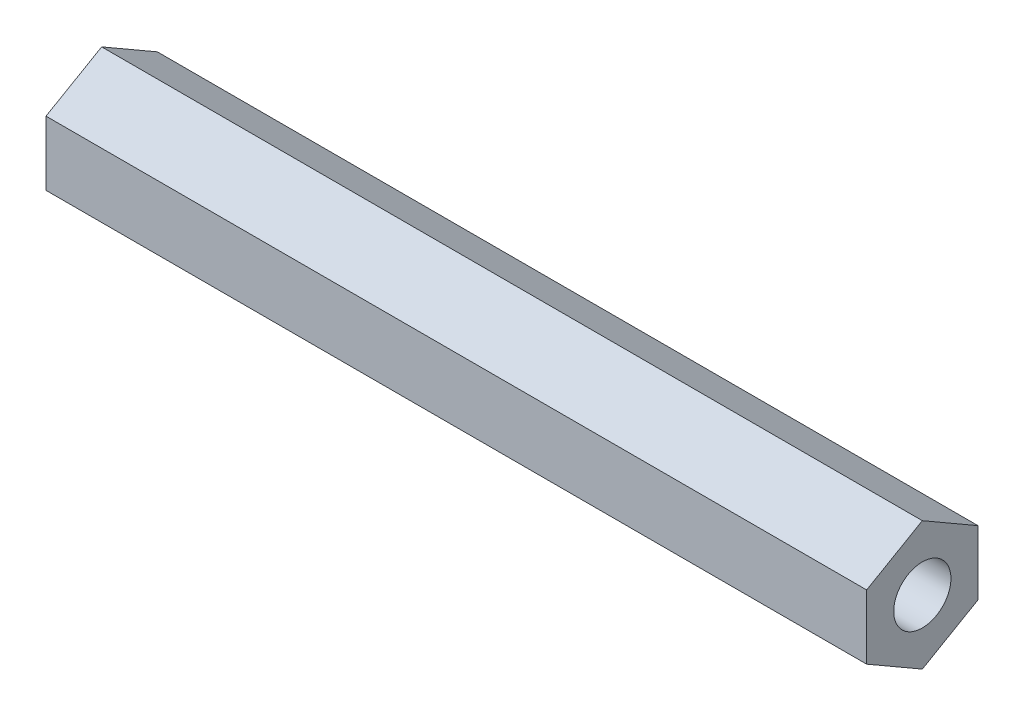
from build123d import *

# Parameters (mm, degrees)
SKETCH1_R           = 3.2639
BOSS_EXTRUDE1_DEPTH = 93.599


with BuildPart() as part:
    # Sketch1 → Boss-Extrude1 (new body)
    with BuildSketch(Plane(origin=(0, 0, 0), x_dir=(0, 0, -1), z_dir=(1, 0, 0))):
        Polygon((0, 7.332348419), (-6.35, 3.666174209), (-6.35, -3.666174209), (0, -7.332348419), (6.35, -3.666174209), (6.35, 3.666174209), align=None)
        Circle(SKETCH1_R, mode=Mode.SUBTRACT)
    extrude(amount=BOSS_EXTRUDE1_DEPTH)


solid = part.part
